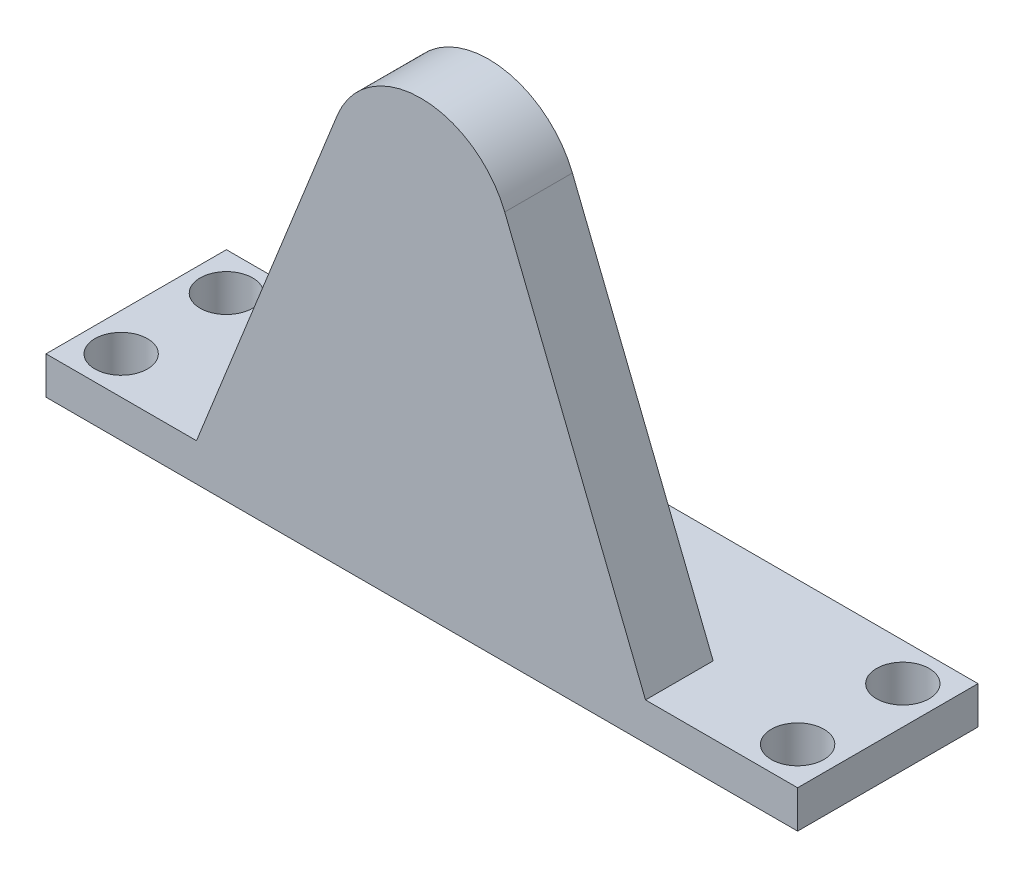
from build123d import *

# Parameters (mm, degrees)
SKETCH1_W           = 100
SKETCH1_H           = 24
SKETCH1_R           = 3.5
BOSS_EXTRUDE1_DEPTH = 5
BOSS_EXTRUDE2_DEPTH = 9
SKETCH3_R           = 8
CUT_EXTRUDE1_DEPTH  = 4


with BuildPart() as part:
    # Sketch1 → Boss-Extrude1 (new body)
    with BuildSketch(Plane(origin=(0, 0, 0), x_dir=(1, 0, 0), z_dir=(0, 1, 0))):
        Rectangle(SKETCH1_W, SKETCH1_H)
        with Locations((-45, 7)):
            Circle(SKETCH1_R, mode=Mode.SUBTRACT)
        with Locations((-45, -7)):
            Circle(SKETCH1_R, mode=Mode.SUBTRACT)
        with Locations((45, 7)):
            Circle(SKETCH1_R, mode=Mode.SUBTRACT)
        with Locations((45, -7)):
            Circle(SKETCH1_R, mode=Mode.SUBTRACT)
    extrude(amount=BOSS_EXTRUDE1_DEPTH)

    # Sketch2 → Boss-Extrude2 (add)
    with BuildSketch(Plane.XY.offset(3)):
        with BuildLine():
            Line((-29.978021695, 5), (29.763516014, 5))
            Line((29.763516014, 5), (11.035619534, 51.854874594))
            ThreePointArc((11.035619534, 51.854874594), (-0.107252841, 59.401067767), (-11.250125215, 51.854874594))
            Line((-11.250125215, 51.854874594), (-29.978021695, 5))
        make_face()
    extrude(amount=BOSS_EXTRUDE2_DEPTH)

    # Sketch3 → Cut-Extrude1 (cut)
    with BuildSketch(Plane(origin=(0, 0, 3), x_dir=(-1, 0, 0), z_dir=(0, 0, -1))):
        with Locations((0, 49.578279074)):
            Circle(SKETCH3_R)
    extrude(amount=-CUT_EXTRUDE1_DEPTH, mode=Mode.SUBTRACT)


solid = part.part
